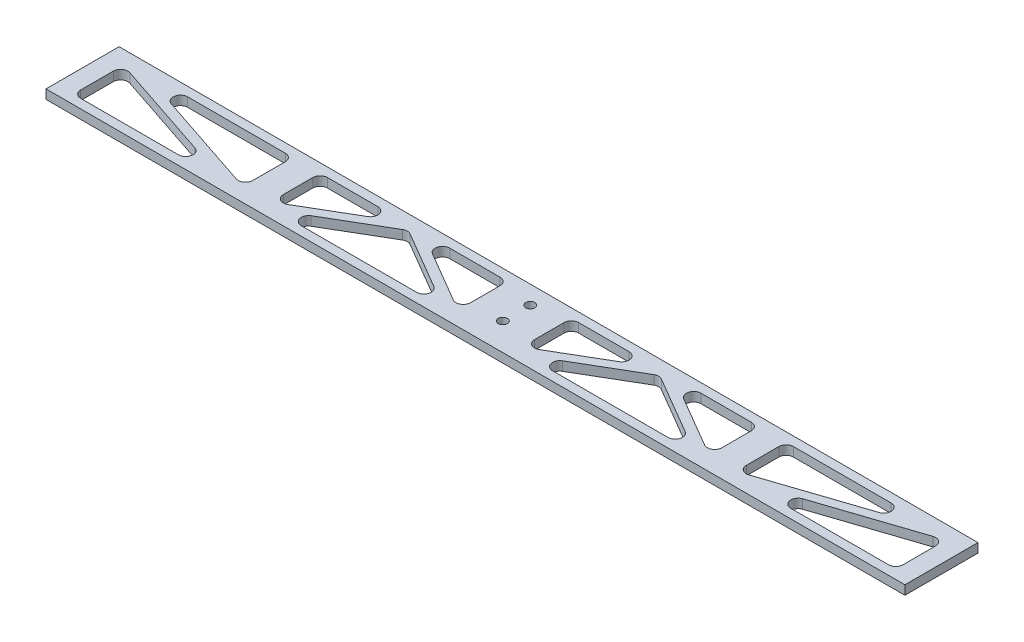
from build123d import *

# Parameters (mm, degrees)
SKETCH1_W           = 298.45
SKETCH1_H           = 25.4
BOSS_EXTRUDE1_DEPTH = 3.175
CUT_EXTRUDE1_DEPTH  = 4.175
SKETCH3_R           = 1.5875
CUT_EXTRUDE2_DEPTH  = 4.175
FILLET1_R           = 2.54


with BuildPart() as part:
    # Sketch1 → Boss-Extrude1 (new body)
    with BuildSketch(Plane(origin=(0, 0, 0), x_dir=(1, 0, 0), z_dir=(0, 1, 0))):
        Rectangle(SKETCH1_W, SKETCH1_H)
    extrude(amount=BOSS_EXTRUDE1_DEPTH)

    # Sketch2 → Cut-Extrude1 (cut, through all)
    with BuildSketch(Plane(origin=(0, 3.175, 0), x_dir=(1, 0, 0), z_dir=(0, 1, 0))):
        Polygon((-142.875, -9.525), (-90.745115786, -9.525), (-142.875, 7.851628071), align=None)
        Polygon((-85.725, -7.851628071), (-85.725, 9.525), (-137.854884214, 9.525), align=None)
        Polygon((-76.2, -7.685517516), (-46.798699244, 9.525), (-76.2, 9.525), align=None)
        Polygon((-73.057550756, -9.525), (-14.254949244, -9.525), (-43.65625, 7.685517516), align=None)
        Polygon((-11.1125, -7.685517516), (-11.1125, 9.525), (-40.513800756, 9.525), align=None)
        Polygon((11.1125, -7.685517516), (40.513800756, 9.525), (11.1125, 9.525), align=None)
        Polygon((14.254949244, -9.525), (73.057550756, -9.525), (43.65625, 7.685517516), align=None)
        Polygon((76.2, -7.685517516), (76.2, 9.525), (46.798699244, 9.525), align=None)
        Polygon((85.725, -7.851628071), (137.854884214, 9.525), (85.725, 9.525), align=None)
        Polygon((90.745115786, -9.525), (142.875, -9.525), (142.875, 7.851628071), align=None)
    extrude(amount=-CUT_EXTRUDE1_DEPTH, mode=Mode.SUBTRACT)

    # Sketch3 → Cut-Extrude2 (cut, through all)
    with BuildSketch(Plane(origin=(0, 3.175, 0), x_dir=(1, 0, 0), z_dir=(0, 1, 0))):
        with Locations((0, 6.35)):
            Circle(SKETCH3_R)
        with Locations((0, -3.175)):
            Circle(SKETCH3_R)
    extrude(amount=-CUT_EXTRUDE2_DEPTH, mode=Mode.SUBTRACT)

    # Fillet1
    fillet1_edges = [part.edges().sort_by_distance(p)[0] for p in [
        (-43.65625, 1.5875, -7.685517516),
        (-14.254949244, 1.5875, 9.525),
        (-73.057550756, 1.5875, 9.525),
        (-40.513800756, 1.5875, -9.525),
        (-11.1125, 1.5875, -9.525),
        (-11.1125, 1.5875, 7.685517516),
        (-76.2, 1.5875, 7.685517516),
        (-76.2, 1.5875, -9.525),
        (-46.798699244, 1.5875, -9.525),
        (-85.725, 1.5875, 7.851628071),
        (-137.854884214, 1.5875, -9.525),
        (-85.725, 1.5875, -9.525),
        (85.725, 1.5875, 7.851628071),
        (85.725, 1.5875, -9.525),
        (137.854884214, 1.5875, -9.525),
        (46.798699244, 1.5875, -9.525),
        (76.2, 1.5875, -9.525),
        (76.2, 1.5875, 7.685517516),
        (11.1125, 1.5875, 7.685517516),
        (11.1125, 1.5875, -9.525),
        (40.513800756, 1.5875, -9.525),
        (43.65625, 1.5875, -7.685517516),
        (73.057550756, 1.5875, 9.525),
        (14.254949244, 1.5875, 9.525),
        (90.745115786, 1.5875, 9.525),
        (142.875, 1.5875, -7.851628071),
        (142.875, 1.5875, 9.525),
        (-90.745115786, 1.5875, 9.525),
        (-142.875, 1.5875, 9.525),
        (-142.875, 1.5875, -7.851628071),
    ]]
    fillet(fillet1_edges, radius=FILLET1_R)


solid = part.part
